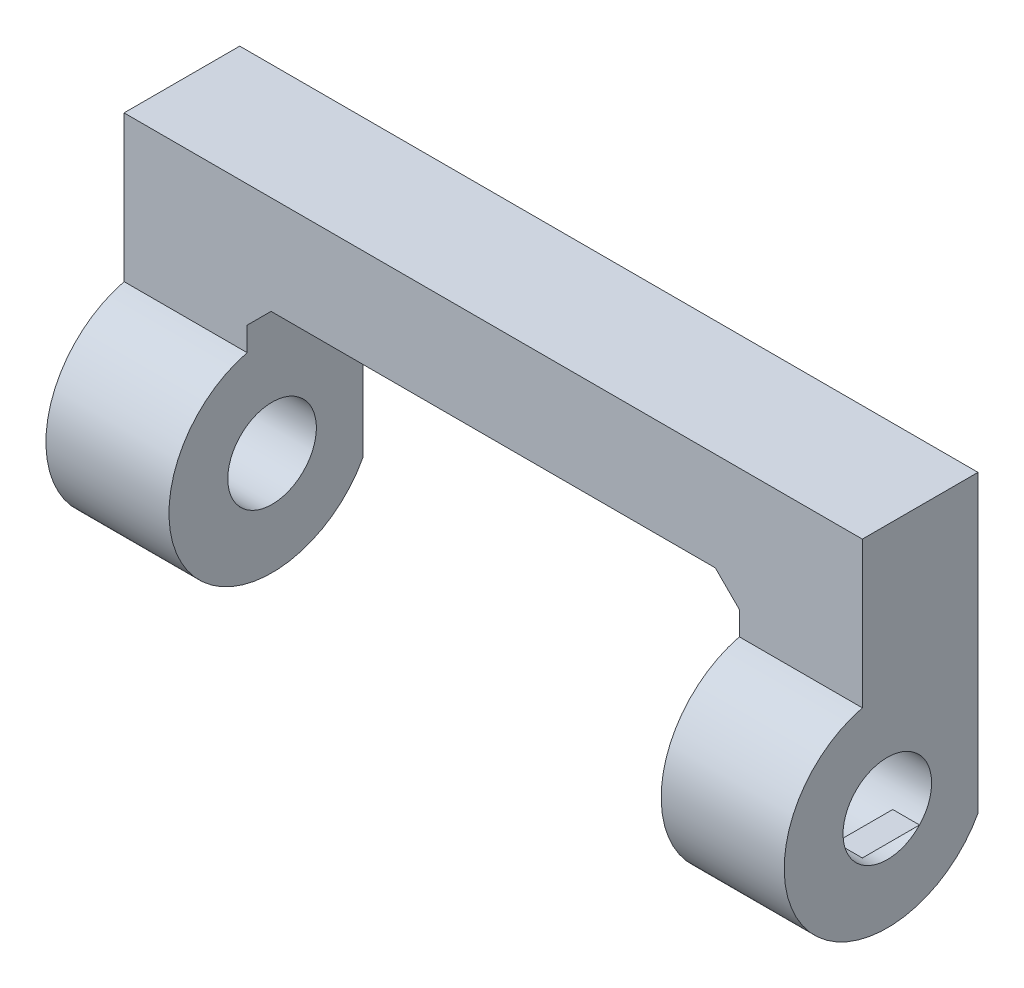
from build123d import *

# Parameters (mm, degrees)
BOSS_EXTRUDE1_DEPTH = 5
CUT_EXTRUDE1_DEPTH  = 31.003999108
SKETCH2_3_R         = 1.799674582
BOSS_EXTRUDE2_DEPTH = 5
SKETCH3_R           = 1.799674582
BOSS_EXTRUDE3_DEPTH = 5
CHAMFER1_SIZE       = 0.3
FILLET1_R           = 0.4


with BuildPart() as part:
    # Model → Boss-Extrude1 (new body)
    with BuildSketch(Plane.XY):
        Polygon((294.639989597, 34.266605248), (295.614474597, 35.240900181), (304.640051213, 35.240024382), (313.667685024, 35.239144856), (314.643988705, 34.264659856), (314.643988705, 28.018126256), (319.643988705, 28.016541689), (319.643988705, 39.239445651), (289.639989597, 39.239424468), (289.639989597, 28.016886869), (294.639989597, 28.020075702), align=None)
    extrude(amount=BOSS_EXTRUDE1_DEPTH)

    # Sketch2 → Cut-Extrude1 (cut, through all)
    with BuildSketch(Plane.ZY.offset(-289.639989597)):
        with BuildLine():
            ThreePointArc((5, 30.738550482), (2.616874768, 30.420409758), (2.676683755, 28.016886869))
            Line((2.676683755, 28.016886869), (5, 28.016886869))
            Line((5, 28.016886869), (5, 30.738550482))
        make_face()
    extrude(amount=-CUT_EXTRUDE1_DEPTH, mode=Mode.SUBTRACT)

    # Sketch2_3 → Boss-Extrude2 (add)
    with BuildSketch(Plane.ZY.offset(-289.639989597)):
        with BuildLine():
            Line((0, 30.526457448), (0, 27.942741433))
            ThreePointArc((0, 27.942741433), (8.175740848, 29.23459944), (0, 30.526457448))
        make_face()
        with Locations((3.985657063, 29.251964795)):
            Circle(SKETCH2_3_R, mode=Mode.SUBTRACT)
    extrude(amount=-BOSS_EXTRUDE2_DEPTH)

    # Sketch3 → Boss-Extrude3 (add)
    with BuildSketch(Plane.ZY.offset(-314.643988705)):
        with BuildLine():
            Line((4.35e-07, 30.526456106), (4.35e-07, 27.942740092))
            ThreePointArc((4.35e-07, 27.942740092), (8.175741283, 29.234598099), (4.35e-07, 30.526456106))
        make_face()
        with Locations((3.985657498, 29.251963453)):
            Circle(SKETCH3_R, mode=Mode.SUBTRACT)
    extrude(amount=-BOSS_EXTRUDE3_DEPTH)

    # Chamfer1
    chamfer1_edges = [part.edges().sort_by_distance(p)[0] for p in [
        (294.639989597, 31.104673341, 0),
        (289.639989597, 33.59108295, 0),
        (304.641989151, 39.239435059, 0),
        (319.643988705, 33.62799367, 0),
        (314.643988705, 31.141393056, 0),
        (314.155836865, 34.751902356, 0),
        (309.153868118, 35.239584619, 0),
        (300.127262905, 35.240462282, 0),
        (295.127232097, 34.753752715, 0),
    ]]
    chamfer(chamfer1_edges, length=CHAMFER1_SIZE)

    # Fillet1
    fillet1_edges = [part.edges().sort_by_distance(p)[0] for p in [
        (317.143988705, 27.942740092, 4.35e-07),
        (292.139989597, 27.942741433, 0),
    ]]
    fillet(fillet1_edges, radius=FILLET1_R)


solid = part.part
